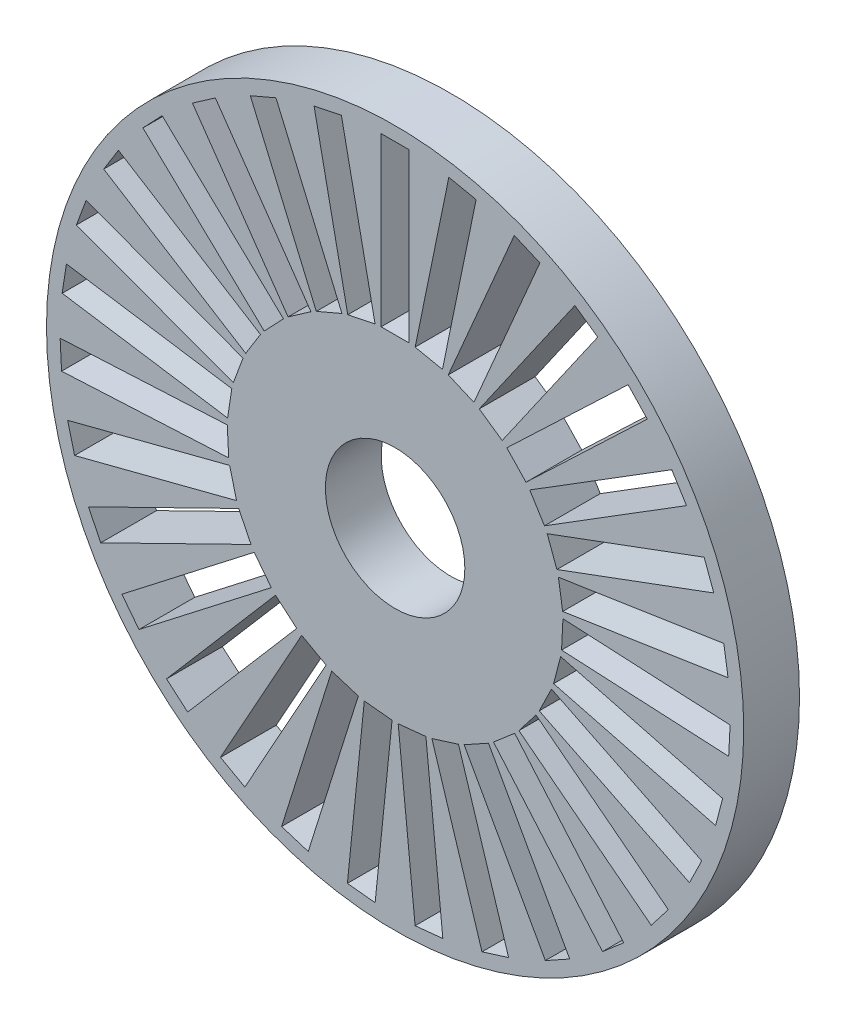
from build123d import *

# Parameters (mm, degrees)
SKIZZE1_R                       = 12.5
SKIZZE1_R_2                     = 2.5
AUFSATZ_LINEAR_AUSTRAGEN1_DEPTH = 2
SKIZZE2_W                       = 1
SKIZZE2_H                       = 6
SCHNITT_LINEAR_AUSTRAGEN1_DEPTH = 2
KREISMUSTER1_COUNT              = 31


with BuildPart() as part:
    # Skizze1 → Aufsatz-Linear austragen1 (new body)
    with BuildSketch(Plane.XY):
        Circle(SKIZZE1_R)
        Circle(SKIZZE1_R_2, mode=Mode.SUBTRACT)
    extrude(amount=AUFSATZ_LINEAR_AUSTRAGEN1_DEPTH)

    # Skizze2 → Schnitt-Linear austragen1 (cut)
    with BuildSketch(Plane.XY.offset(2)):
        with Locations((0, 9)):
            Rectangle(SKIZZE2_W, SKIZZE2_H)
    schnitt_linear_austragen1 = extrude(amount=-SCHNITT_LINEAR_AUSTRAGEN1_DEPTH, mode=Mode.SUBTRACT)

    # Kreismuster1: Schnitt-Linear austragen1 ×31 about axis
    kreismuster1_axis = Axis((0, 0, 0), (0, 0, 1))
    for i in range(1, KREISMUSTER1_COUNT):
        add(schnitt_linear_austragen1.rotate(kreismuster1_axis, i * 360 / KREISMUSTER1_COUNT), mode=Mode.SUBTRACT)


solid = part.part
